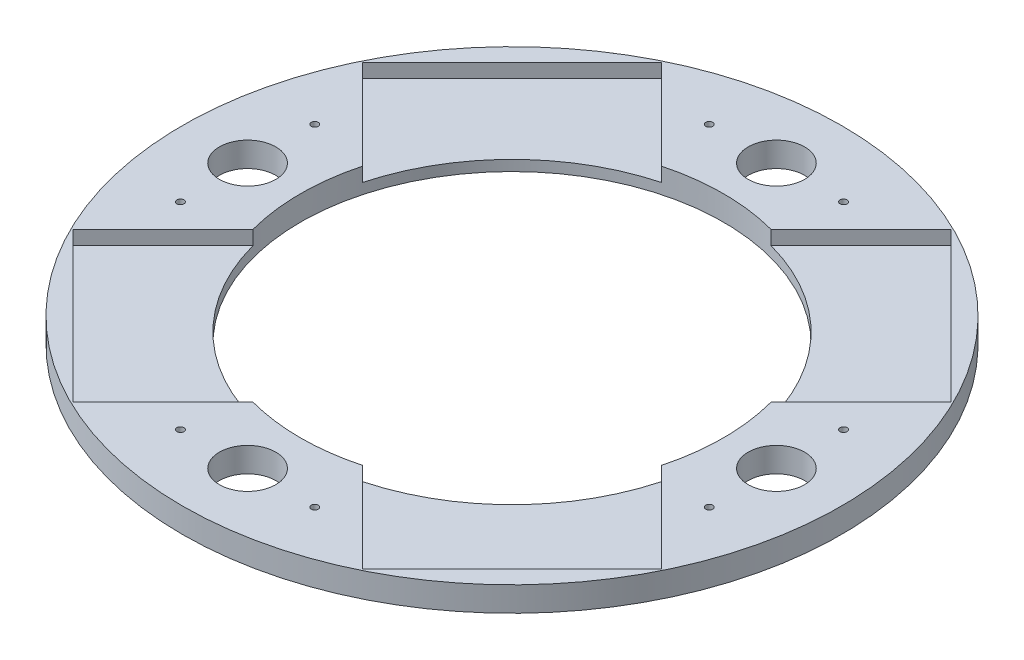
from build123d import *

# Parameters (mm, degrees)
SKETCH2_R             = 93.485122645
EXTRUDE1_DEPTH        = 7
SKETCH3_R             = 8
CUT_EXTRUDE1_DEPTH    = 8
F_3_48_TAPPED_HOLE1_D = 1.9939
CIRPATTERN1_COUNT     = 4
SKETCH8_R             = 60
CUT_EXTRUDE2_DEPTH    = 8
SKETCH9_R             = 60
CUT_EXTRUDE10_DEPTH   = 4
CIRPATTERN4_COUNT     = 4


with BuildPart() as part:
    # Sketch2 → Extrude1 (new body)
    with BuildSketch(Plane(origin=(0, 0, 0), x_dir=(1, 0, 0), z_dir=(0, 1, 0))):
        Circle(SKETCH2_R)
    extrude(amount=EXTRUDE1_DEPTH)

    # Sketch3 → Cut-Extrude1 (cut, through all)
    with BuildSketch(Plane(origin=(0, 7, 0), x_dir=(1, 0, 0), z_dir=(0, 1, 0))):
        with Locations((0, 75)):
            Circle(SKETCH3_R)
    cut_extrude1 = extrude(amount=-CUT_EXTRUDE1_DEPTH, mode=Mode.SUBTRACT)

    # #3-48 Tapped Hole1 (through all)
    with Locations(Plane(origin=(0, 7, 0), x_dir=(1, 0, 0), z_dir=(0, 1, 0))):
        with Locations((-19.05, 75), (19.05, 75)):
            f_3_48_tapped_hole1 = Hole(F_3_48_TAPPED_HOLE1_D / 2)

    # CirPattern1: Cut-Extrude1, #3-48 Tapped Hole1 ×4 about axis
    cirpattern1_axis = Axis((0, 0, 0), (0, 1, 0))
    for i in range(1, CIRPATTERN1_COUNT):
        add(cut_extrude1.rotate(cirpattern1_axis, i * 360 / CIRPATTERN1_COUNT), mode=Mode.SUBTRACT)
        add(f_3_48_tapped_hole1.rotate(cirpattern1_axis, i * 360 / CIRPATTERN1_COUNT), mode=Mode.SUBTRACT)

    # Sketch8 → Cut-Extrude2 (cut, through all)
    with BuildSketch(Plane(origin=(0, 7, 0), x_dir=(1, 0, 0), z_dir=(0, 1, 0))):
        Circle(SKETCH8_R)
    extrude(amount=-CUT_EXTRUDE2_DEPTH, mode=Mode.SUBTRACT)

    # Sketch9 → Cut-Extrude10 (cut)
    with BuildSketch(Plane(origin=(0, 7, 0), x_dir=(1, 0, 0), z_dir=(0, 1, 0))):
        Circle(SKETCH9_R)
        Polygon((41.044204571, -83.470611442), (83.470611442, -41.044204571), (42.459618294, -0.033211423), (-0.033211423, -42.393195448), align=None)
    cut_extrude10 = extrude(amount=-CUT_EXTRUDE10_DEPTH, mode=Mode.SUBTRACT)

    # CirPattern4: Cut-Extrude10 ×4 about axis
    cirpattern4_axis = Axis((0, 0, 0), (0, 1, 0))
    for i in range(1, CIRPATTERN4_COUNT):
        add(cut_extrude10.rotate(cirpattern4_axis, i * 360 / CIRPATTERN4_COUNT), mode=Mode.SUBTRACT)


solid = part.part
